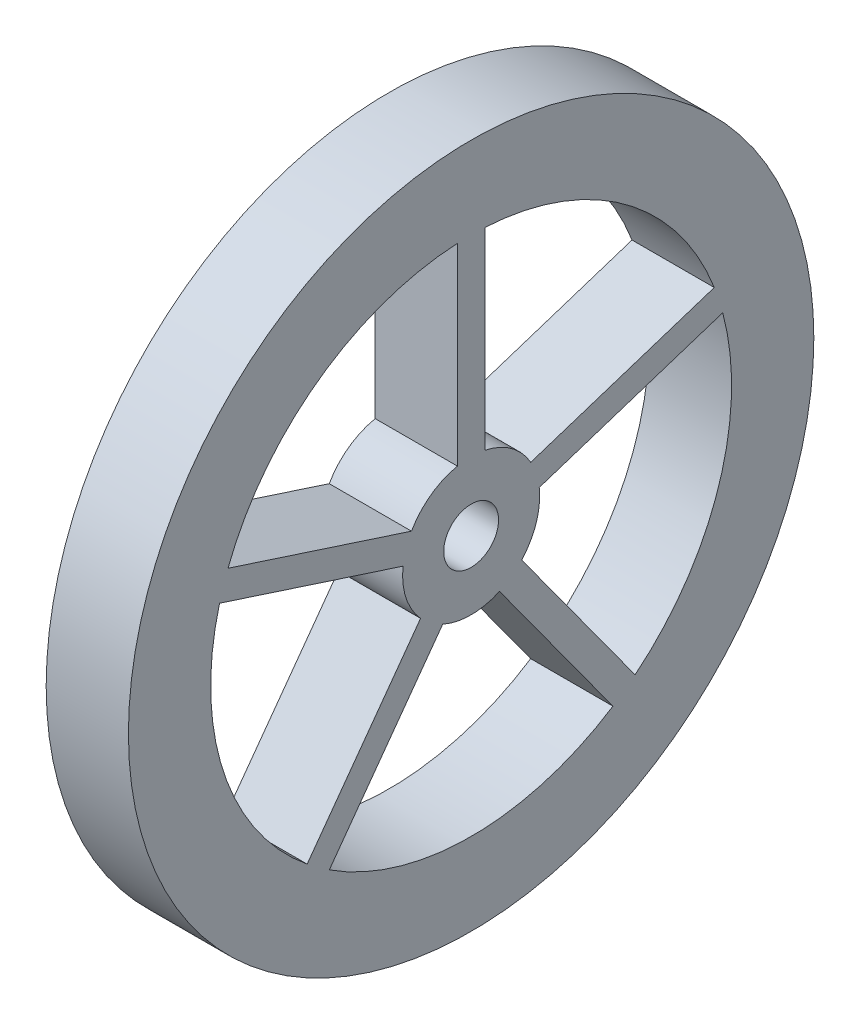
from build123d import *

# Parameters (mm, degrees)
SKETCH1_R           = 250
SKETCH1_R_2         = 20
BOSS_EXTRUDE1_DEPTH = 60


with BuildPart() as part:
    # Sketch1 → Boss-Extrude1 (new body)
    with BuildSketch(Plane(origin=(0, 0, 0), x_dir=(0, 0, -1), z_dir=(1, 0, 0))):
        Circle(SKETCH1_R)
        Circle(SKETCH1_R_2, mode=Mode.SUBTRACT)
        with BuildLine():
            Line((177.360116559, 68.142417438), (43.501893686, 24.649244324))
            ThreePointArc((43.501893686, 24.649244324), (29.389262615, 40.450849719), (10, 48.989794856))
            Line((10, 48.989794856), (10, 189.73665961))
            ThreePointArc((10, 189.73665961), (111.679197936, 153.713228931), (177.360116559, 68.142417438))
        make_face(mode=Mode.SUBTRACT)
        with BuildLine():
            Line((-10, 189.73665961), (-10, 48.989794856))
            ThreePointArc((-10, 48.989794856), (-29.389262615, 40.450849719), (-43.501893686, 24.649244324))
            Line((-43.501893686, 24.649244324), (-177.360116559, 68.142417438))
            ThreePointArc((-177.360116559, 68.142417438), (-111.679197936, 153.713228931), (-10, 189.73665961))
        make_face(mode=Mode.SUBTRACT)
        with BuildLine():
            Line((183.540456446, 49.121287113), (49.682233573, 5.628113998))
            ThreePointArc((49.682233573, 5.628113998), (47.552825815, -15.450849719), (36.885648873, -33.755724066))
            Line((36.885648873, -33.755724066), (119.614580282, -147.622329558))
            ThreePointArc((119.614580282, -147.622329558), (180.700738096, -58.713228931), (183.540456446, 49.121287113))
        make_face(mode=Mode.SUBTRACT)
        with BuildLine():
            Line((103.434240394, -159.378034603), (20.705308985, -45.511429112))
            ThreePointArc((20.705308985, -45.511429112), (0, -50), (-20.705308985, -45.511429112))
            Line((-20.705308985, -45.511429112), (-103.434240394, -159.378034603))
            ThreePointArc((-103.434240394, -159.378034603), (0, -190), (103.434240394, -159.378034603))
        make_face(mode=Mode.SUBTRACT)
        with BuildLine():
            Line((-119.614580282, -147.622329558), (-36.885648873, -33.755724066))
            ThreePointArc((-36.885648873, -33.755724066), (-47.552825815, -15.450849719), (-49.682233573, 5.628113998))
            Line((-49.682233573, 5.628113998), (-183.540456446, 49.121287113))
            ThreePointArc((-183.540456446, 49.121287113), (-180.700738096, -58.713228931), (-119.614580282, -147.622329558))
        make_face(mode=Mode.SUBTRACT)
    extrude(amount=BOSS_EXTRUDE1_DEPTH)


solid = part.part
